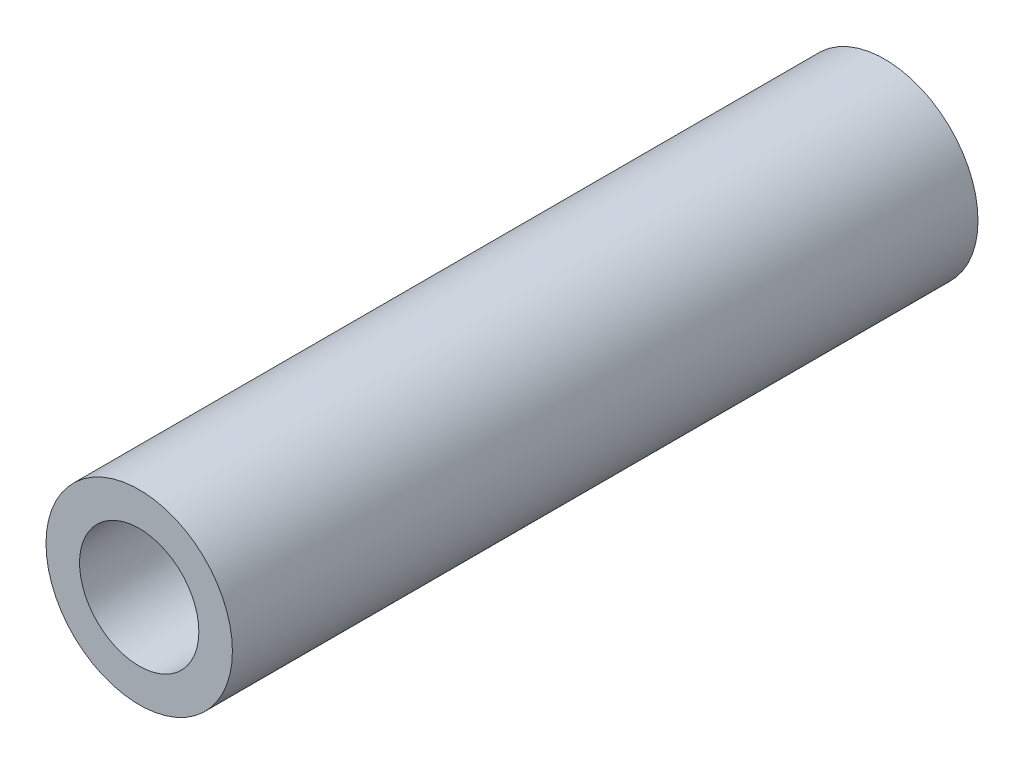
from build123d import *

# Parameters (mm, degrees)
SKETCH1_R           = 2.5
SKETCH1_R_2         = 1.6
BOSS_EXTRUDE1_DEPTH = 20


with BuildPart() as part:
    # Sketch1 → Boss-Extrude1 (new body)
    with BuildSketch(Plane.XY):
        Circle(SKETCH1_R)
        Circle(SKETCH1_R_2, mode=Mode.SUBTRACT)
    extrude(amount=BOSS_EXTRUDE1_DEPTH)


solid = part.part
